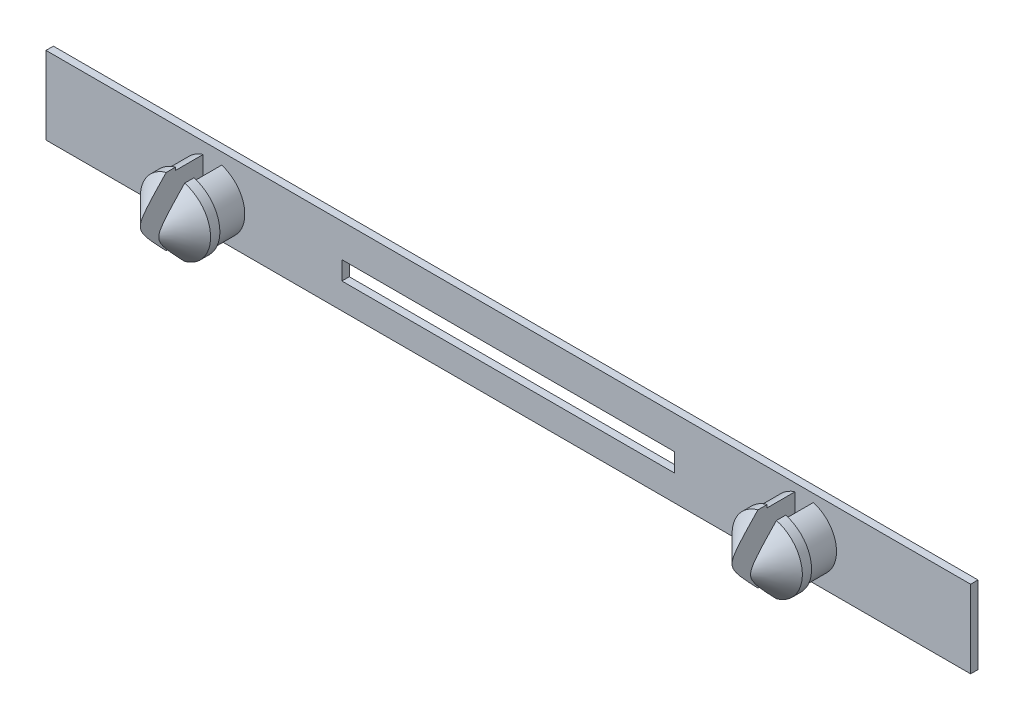
from build123d import *

# Parameters (mm, degrees)
SKICA2_W                 = 50
SKICA2_H                 = 4.2
SKICA2_W_2               = 18
SKICA2_H_2               = 1
P_IDAT_VYSUNUT_M2_DEPTH  = 0.4
SKICA3_R                 = 1.75
P_IDAT_VYSUNUT_M3_DEPTH  = 1.5
SKICA5_R                 = 1.9
P_IDAT_VYSUNUT_M5_DEPTH  = 2
ZKOSEN_2_SIZE            = 1.5
SKICA7_W                 = 1
SKICA7_H                 = 5
ODEBRAT_VYSUNUT_M1_DEPTH = 3.5


with BuildPart() as part:
    # Skica2 → Přidat vysunutím2 (new body)
    with BuildSketch(Plane.XY):
        Rectangle(SKICA2_W, SKICA2_H)
        with Locations((0, -0.2)):
            Rectangle(SKICA2_W_2, SKICA2_H_2, mode=Mode.SUBTRACT)
    extrude(amount=P_IDAT_VYSUNUT_M2_DEPTH)

    # Skica3 → Přidat vysunutím3 (add)
    with BuildSketch(Plane.XY.offset(0.4)):
        with Locations((-16, -0.2)):
            Circle(SKICA3_R)
        with Locations((16, 0)):
            Circle(SKICA3_R)
    extrude(amount=P_IDAT_VYSUNUT_M3_DEPTH)

    # Skica5 → Přidat vysunutím5 (add)
    with BuildSketch(Plane.XY.offset(1.9)):
        with Locations((-16, -0.2)):
            Circle(SKICA5_R)
        with Locations((16, 0)):
            Circle(SKICA5_R)
    extrude(amount=P_IDAT_VYSUNUT_M5_DEPTH)

    # Zkosení2
    zkosen_2_edges = [part.edges().sort_by_distance(p)[0] for p in [
        (-17.9, -0.2, 3.9),
        (14.1, 0, 3.9),
    ]]
    chamfer(zkosen_2_edges, length=ZKOSEN_2_SIZE)

    # Skica7 → Odebrat vysunutím1 (cut)
    with BuildSketch(Plane.XY.offset(3.9)):
        with Locations((-16, -0.2)):
            Rectangle(SKICA7_W, SKICA7_H)
        with Locations((16, 0)):
            Rectangle(SKICA7_W, SKICA7_H)
    extrude(amount=-ODEBRAT_VYSUNUT_M1_DEPTH, mode=Mode.SUBTRACT)


solid = part.part
